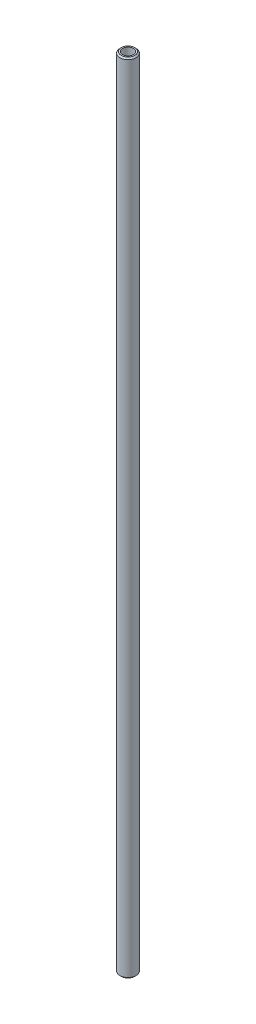
from build123d import *

# Parameters (mm, degrees)
ESQUISSE2_R        = 3
ESQUISSE2_R_2      = 2
BOSS_EXTRU_1_DEPTH = 295
CHANFREIN1_SIZE    = 0.5


with BuildPart() as part:
    # Esquisse2 → Boss.-Extru.1 (new body)
    with BuildSketch(Plane(origin=(0, 0, 0), x_dir=(1, 0, 0), z_dir=(0, 1, 0))):
        with Locations((5628.342775437, -596.213783271)):
            Circle(ESQUISSE2_R)
        with Locations((5628.342775437, -596.213783271)):
            Circle(ESQUISSE2_R_2, mode=Mode.SUBTRACT)
    extrude(amount=BOSS_EXTRU_1_DEPTH)

    # Chanfrein1
    chanfrein1_edges = [part.edges().sort_by_distance(p)[0] for p in [
        (5625.342775437, 0, 596.213783271),
        (5625.342775437, 295, 596.213783271),
    ]]
    chamfer(chanfrein1_edges, length=CHANFREIN1_SIZE)


solid = part.part
